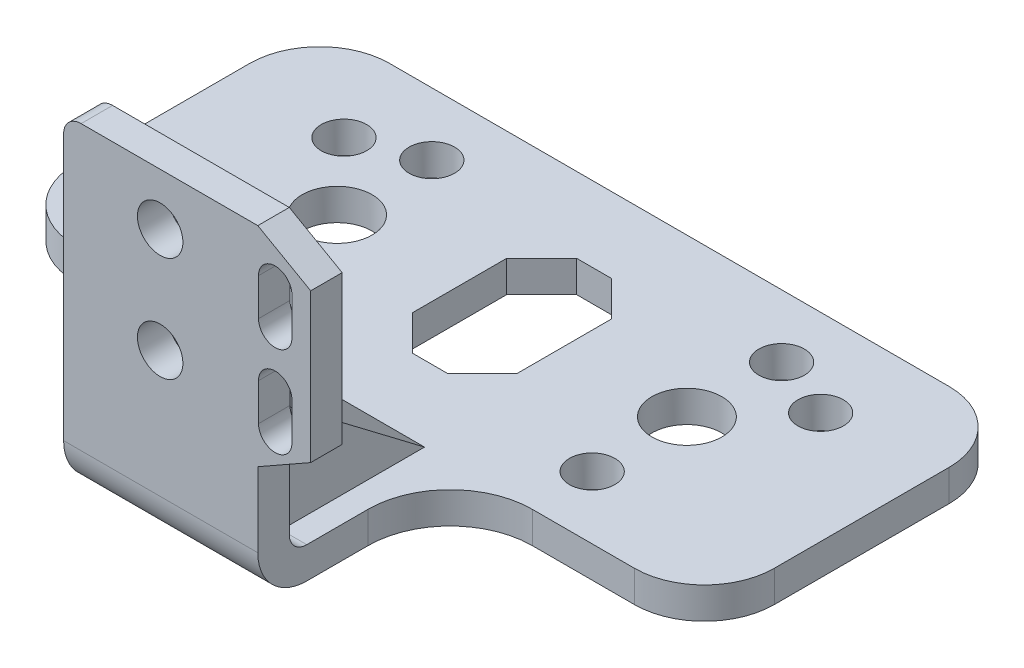
from build123d import *

# Parameters (mm, degrees)
BOSS_EXTRUDE1_DEPTH       = 50
SKETCH2_OUTSIDE_W         = 128.57
SKETCH2_OUTSIDE_H         = 103.57
SKETCH2_OUTSIDE_R         = 5
SKETCH2_OUTSIDE_R_2       = 3.25
CUT_EXTRUDE34_DEPTH       = 46
CUT_EXTRUDE34_DEPTH_BACK  = 1
BOSS_EXTRUDE3_DEPTH       = 4.5
SUPPORT_DEPTH             = 10
FILLET3_R                 = 2.5
FILLET4_R                 = 7
SKETCH6_R                 = 3.25
LOADCELL_MOUNT_DEPTH      = 1
LOADCELL_MOUNT_DEPTH_BACK = 73.5
WIREHOLE_DEPTH            = 5.18
SKETCH9_R                 = 6.912708826
CUT_EXTRUDE35_DEPTH       = 10


with BuildPart() as part:
    # Sketch1 → Boss-Extrude1 (new body, symmetric)
    with BuildSketch(Plane(origin=(0, 0, 0), x_dir=(0, 0, -1), z_dir=(1, 0, 0))):
        Polygon((0, 0), (0, 45), (4.5, 45), (4.5, 4.5), (75, 4.5), (75, 0), align=None)
    extrude(amount=BOSS_EXTRUDE1_DEPTH, both=True)

    # Sketch2 outside → Cut-Extrude34 (cut, two sides)
    with BuildSketch(Plane(origin=(0, 0, 0), x_dir=(1, 0, 0), z_dir=(0, 1, 0))) as cut_extrude34_sk:
        with Locations((0, 37.5)):
            Rectangle(SKETCH2_OUTSIDE_W, SKETCH2_OUTSIDE_H)
        with BuildLine():
            Line((-40, 30), (-25.836010131, 30))
            ThreePointArc((-25.836010131, 30), (-17.535836731, 26.561955607), (-14.097792338, 18.261782207))
            Line((-14.097792338, 18.261782207), (-14.097792338, 7))
            Line((-14.097792338, 7), (13.661782207, 7))
            Line((13.661782207, 7), (13.661782207, 18.261782207))
            ThreePointArc((13.661782207, 18.261782207), (17.099826599, 26.561955607), (25.4, 30))
            Line((25.4, 30), (40, 30))
            ThreePointArc((40, 30), (47.071067812, 32.928932188), (50, 40))
            Line((50, 40), (50, 65))
            ThreePointArc((50, 65), (47.071067812, 72.071067812), (40, 75))
            Line((40, 75), (-40, 75))
            ThreePointArc((-40, 75), (-47.071067812, 72.071067812), (-50, 65))
            Line((-50, 65), (-50, 40))
            ThreePointArc((-50, 40), (-47.071067812, 32.928932188), (-40, 30))
        make_face(mode=Mode.SUBTRACT)
        with Locations((-25, 52.5)):
            Circle(SKETCH2_OUTSIDE_R)
        with Locations((25, 52.5)):
            Circle(SKETCH2_OUTSIDE_R)
        with Locations((25, 66.04)):
            Circle(SKETCH2_OUTSIDE_R_2)
        with Locations((25, 38.96)):
            Circle(SKETCH2_OUTSIDE_R_2)
        with Locations((34.072580566, 62.550864733)):
            Circle(SKETCH2_OUTSIDE_R_2)
        with Locations((-25, 66.04)):
            Circle(SKETCH2_OUTSIDE_R_2)
        with Locations((-25, 38.96)):
            Circle(SKETCH2_OUTSIDE_R_2)
        with Locations((-34.072580566, 62.550864733)):
            Circle(SKETCH2_OUTSIDE_R_2)
        Polygon((-2.5, 64.24), (2.5, 64.24), (7.5, 59.24), (7.5, 45.76), (2.5, 40.76), (-2.5, 40.76), (-7.5, 45.76), (-7.5, 59.24), align=None)
    extrude(amount=CUT_EXTRUDE34_DEPTH, mode=Mode.SUBTRACT)
    extrude(cut_extrude34_sk.sketch, amount=-CUT_EXTRUDE34_DEPTH_BACK, mode=Mode.SUBTRACT)

    # Sketch4 → Boss-Extrude3 (add)
    with BuildSketch(Plane.XY.offset(-7)):
        with BuildLine():
            Line((-14.097792338, 0), (-14.097792338, 45))
            ThreePointArc((-14.097792338, 45), (-13.365559291, 46.767766953), (-11.597792338, 47.5))
            Line((-11.597792338, 47.5), (13.661782207, 47.5))
            Line((13.661782207, 47.5), (21.222778521, 43.209368433))
            Line((21.222778521, 43.209368433), (21.222778521, 21.944029683))
            Line((21.222778521, 21.944029683), (13.661782207, 17.653398116))
            Line((13.661782207, 17.653398116), (13.661782207, 4.5))
            Line((13.661782207, 4.5), (13.661782207, 0))
            Line((13.661782207, 0), (-14.097792338, 0))
        make_face()
    extrude(amount=BOSS_EXTRUDE3_DEPTH)

    # Sketch → Support (add, symmetric)
    with BuildSketch(Plane(origin=(0, 0, 0), x_dir=(0, 0, -1), z_dir=(1, 0, 0))):
        Polygon((7, 21.944029683), (30, 4.5), (7, 4.5), align=None)
    extrude(amount=SUPPORT_DEPTH, both=True)

    # Fillet3
    fillet3_edges = [part.edges().sort_by_distance(p)[0] for p in [
        (11.830891103, 4.5, -7),
    ]]
    fillet(fillet3_edges, radius=FILLET3_R)

    # Fillet4
    fillet4_edges = [part.edges().sort_by_distance(p)[0] for p in [
        (-0.218005066, 0, -2.5),
    ]]
    fillet(fillet4_edges, radius=FILLET4_R)

    # Sketch6 → LoadCell_Mount (cut, two sides)
    with BuildSketch(Plane.XY.offset(-2.5)) as loadcell_mount_sk:
        with Locations((-0.297792338, 40.083077312)):
            Circle(SKETCH6_R)
        with Locations((-0.297792338, 25.083077312)):
            Circle(SKETCH6_R)
    extrude(amount=LOADCELL_MOUNT_DEPTH, mode=Mode.SUBTRACT)
    extrude(loadcell_mount_sk.sketch, amount=-LOADCELL_MOUNT_DEPTH_BACK, mode=Mode.SUBTRACT)

    # Sketch7 → WireHole (cut)
    with BuildSketch(Plane.XY.offset(-2.5)):
        with BuildLine():
            Line((18.539617084, 41.355633115), (18.539617084, 36.032215871))
            ThreePointArc((18.539617084, 36.032215871), (16.149617084, 33.642215871), (13.759617084, 36.032215871))
            Line((13.759617084, 36.032215871), (13.759617084, 41.355633115))
            ThreePointArc((13.759617084, 41.355633115), (16.149617084, 43.745633115), (18.539617084, 41.355633115))
        make_face()
        with BuildLine():
            Line((18.539617084, 28.355633115), (18.539617084, 23.032215871))
            ThreePointArc((18.539617084, 23.032215871), (16.149617084, 20.642215871), (13.759617084, 23.032215871))
            Line((13.759617084, 23.032215871), (13.759617084, 28.355633115))
            ThreePointArc((13.759617084, 28.355633115), (16.149617084, 30.745633115), (18.539617084, 28.355633115))
        make_face()
    extrude(amount=-WIREHOLE_DEPTH, mode=Mode.SUBTRACT)

    # Sketch9 → Cut-Extrude35 (cut)
    with BuildSketch(Plane(origin=(0, 0, -7), x_dir=(-1, 0, 0), z_dir=(0, 0, -1))):
        with Locations((0, 24.75)):
            Circle(SKETCH9_R)
    extrude(amount=CUT_EXTRUDE35_DEPTH, mode=Mode.SUBTRACT)


solid = part.part
